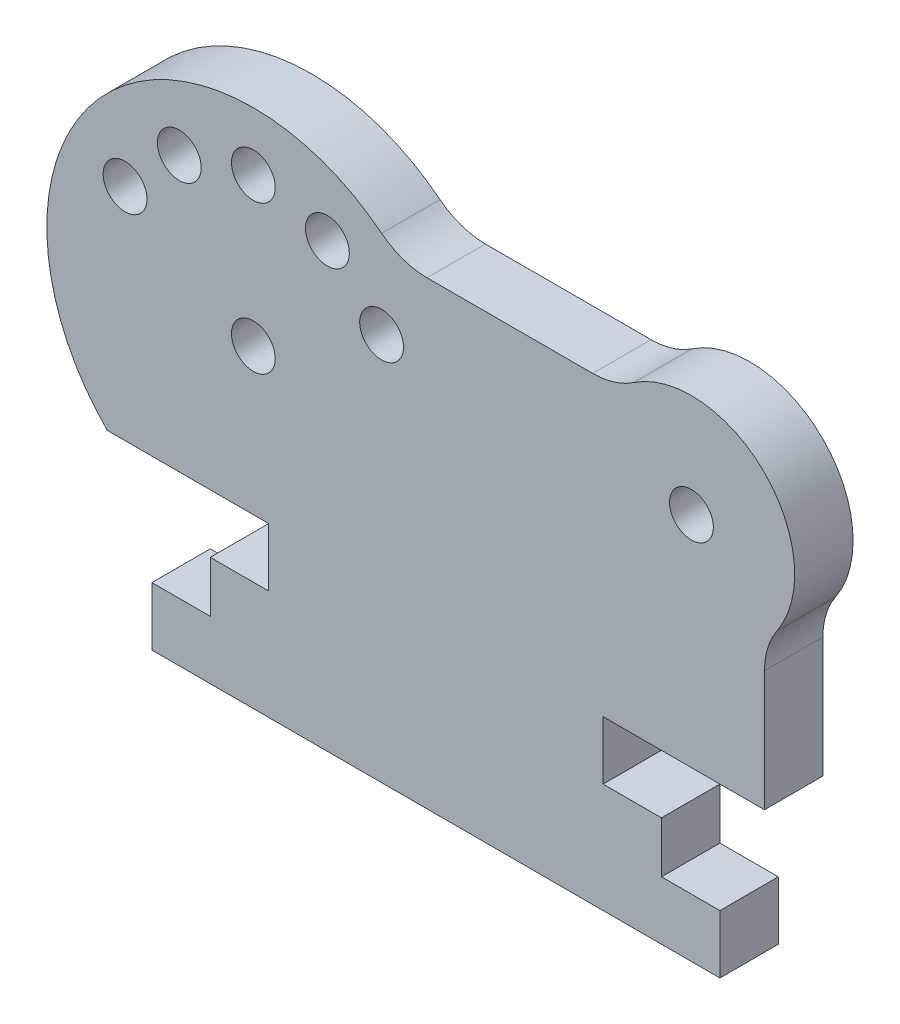
from build123d import *

# Parameters (mm, degrees)
SKETCH2_R           = 1.5
BOSS_EXTRUDE1_DEPTH = 4
FILLET1_R           = 5


with BuildPart() as part:
    # Sketch2 → Boss-Extrude1 (new body)
    with BuildSketch(Plane.XY):
        with BuildLine():
            Line((0, 4), (0, 0))
            Line((0, 0), (38.9, 0))
            Line((38.9, 0), (38.9, 4))
            Line((38.9, 4), (34.9, 4))
            Line((34.9, 4), (34.9, 7.5))
            Line((34.9, 7.5), (30.9, 7.5))
            Line((30.9, 7.5), (30.9, 11.5))
            Line((30.9, 11.5), (41.95, 11.5))
            Line((41.95, 11.5), (41.95, 21.5))
            ThreePointArc((41.95, 21.5), (41.95, 31.5), (31.95, 31.5))
            Line((31.95, 31.5), (16.95, 31.5))
            ThreePointArc((16.95, 31.5), (-3.05, 31.5), (-3.05, 11.5))
            Line((-3.05, 11.5), (8, 11.5))
            Line((8, 11.5), (8, 7.5))
            Line((8, 7.5), (4, 7.5))
            Line((4, 7.5), (4, 4))
            Line((4, 4), (0, 4))
        make_face()
        with Locations((12.021067812, 30.283347099)):
            Circle(SKETCH2_R, mode=Mode.SUBTRACT)
        with Locations((6.95, 31.642135624)):
            Circle(SKETCH2_R, mode=Mode.SUBTRACT)
        with Locations((1.878932188, 30.283347099)):
            Circle(SKETCH2_R, mode=Mode.SUBTRACT)
        with Locations((-1.833347099, 26.571067812)):
            Circle(SKETCH2_R, mode=Mode.SUBTRACT)
        with Locations((15.733347099, 26.571067812)):
            Circle(SKETCH2_R, mode=Mode.SUBTRACT)
        with Locations((6.95, 21.5)):
            Circle(SKETCH2_R, mode=Mode.SUBTRACT)
        with Locations((36.95, 26.5)):
            Circle(SKETCH2_R, mode=Mode.SUBTRACT)
    extrude(amount=BOSS_EXTRUDE1_DEPTH)

    # Fillet1
    fillet1_edges = [part.edges().sort_by_distance(p)[0] for p in [
        (16.95, 31.5, 2),
        (31.95, 31.5, 2),
        (41.95, 21.5, 2),
    ]]
    fillet(fillet1_edges, radius=FILLET1_R)


solid = part.part
